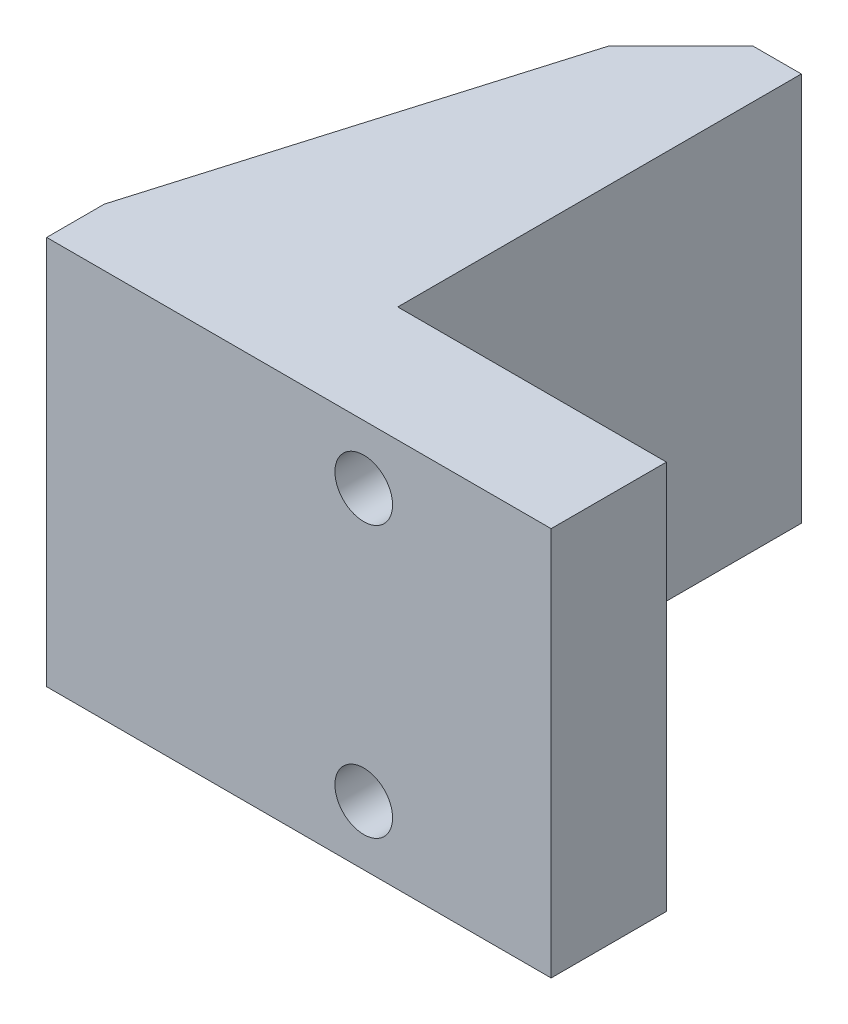
from build123d import *

# Parameters (mm, degrees)
SKETCH1_W           = 17.145
SKETCH1_H           = 17.145
BOSS_EXTRUDE1_DEPTH = 5.08
SKETCH2_R           = 1.27
CUT_EXTRUDE1_DEPTH  = 6.08
SKETCH3_R           = 2.54
CUT_EXTRUDE4_DEPTH  = 2.54
SKETCH4_W           = 6.307704678
SKETCH4_H           = 17.145
BOSS_EXTRUDE2_DEPTH = 17.78
SKETCH5_W           = 2.54
SKETCH5_H           = 17.145
BOSS_EXTRUDE3_DEPTH = 5.08
CHAMFER1_SIZE       = 3.175
BOSS_EXTRUDE4_DEPTH = 2.54
BOSS_EXTRUDE5_DEPTH = 2.54
SKETCH9_W           = 1
SKETCH9_H           = 17.145
CUT_EXTRUDE5_DEPTH  = 17.78


with BuildPart() as part:
    # Sketch1 → Boss-Extrude1 (new body)
    with BuildSketch(Plane.XY):
        with Locations((8.5725, -8.5725)):
            Rectangle(SKETCH1_W, SKETCH1_H)
    extrude(amount=BOSS_EXTRUDE1_DEPTH)

    # Sketch2 → Cut-Extrude1 (cut, through all)
    with BuildSketch(Plane(origin=(0, 0, 0), x_dir=(-1, 0, 0), z_dir=(0, 0, -1))):
        with Locations((-8.89, -2.5908)):
            Circle(SKETCH2_R)
        with Locations((-8.89, -14.5288)):
            Circle(SKETCH2_R)
    extrude(amount=-CUT_EXTRUDE1_DEPTH, mode=Mode.SUBTRACT)

    # Sketch3 → Cut-Extrude4 (cut)
    with BuildSketch(Plane(origin=(0, 0, 0), x_dir=(-1, 0, 0), z_dir=(0, 0, -1))):
        with Locations((-8.89, -2.5908)):
            Circle(SKETCH3_R)
        with Locations((-8.89, -14.5288)):
            Circle(SKETCH3_R)
    extrude(amount=-CUT_EXTRUDE4_DEPTH, mode=Mode.SUBTRACT)

    # Sketch4 → Boss-Extrude2 (add)
    with BuildSketch(Plane(origin=(0, 0, 0), x_dir=(-1, 0, 0), z_dir=(0, 0, -1))):
        with Locations((-3.153852339, -8.5725)):
            Rectangle(SKETCH4_W, SKETCH4_H)
    extrude(amount=BOSS_EXTRUDE2_DEPTH)

    # Sketch5 → Boss-Extrude3 (add)
    with BuildSketch(Plane.ZY):
        with Locations((3.81, -8.5725)):
            Rectangle(SKETCH5_W, SKETCH5_H)
    extrude(amount=BOSS_EXTRUDE3_DEPTH)

    # Chamfer1
    chamfer1_edges = [part.edges().sort_by_distance(p)[0] for p in [
        (0, -8.5725, -17.78),
    ]]
    chamfer(chamfer1_edges, length=CHAMFER1_SIZE)

    # Sketch7 → Boss-Extrude4 (add)
    with BuildSketch(Plane(origin=(0, 0, 0), x_dir=(1, 0, 0), z_dir=(0, 1, 0))):
        Polygon((-5.08, -2.54), (0, 14.605), (0, -2.54), align=None)
    extrude(amount=-BOSS_EXTRUDE4_DEPTH)

    # Sketch8 → Boss-Extrude5 (add)
    with BuildSketch(Plane.XZ.offset(17.145)):
        Polygon((0, 2.54), (-5.08, 2.54), (0, -14.605), align=None)
    extrude(amount=-BOSS_EXTRUDE5_DEPTH)

    # Sketch9 → Cut-Extrude5 (cut)
    with BuildSketch(Plane(origin=(0, 0, -17.78), x_dir=(-1, 0, 0), z_dir=(0, 0, -1))):
        with Locations((-5.807704678, -8.5725)):
            Rectangle(SKETCH9_W, SKETCH9_H)
    extrude(amount=-CUT_EXTRUDE5_DEPTH, mode=Mode.SUBTRACT)


solid = part.part
